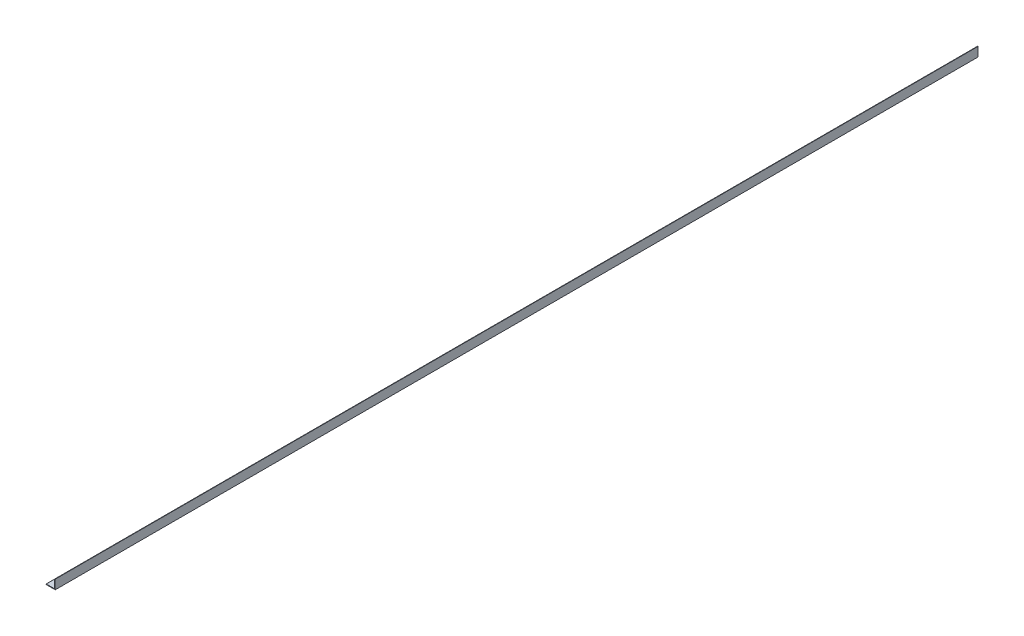
from build123d import *

# Parameters (mm, degrees)
BOSS_EXTRUDE1_DEPTH     = 1270
F_1_4_20_TAPPED_HOLE1_D = 5.1054
CUT_EXTRUDE1_DEPTH      = 2.5875


with BuildPart() as part:
    # Sketch2 → Boss-Extrude1 (new body, symmetric)
    with BuildSketch(Plane.XY):
        with BuildLine():
            Line((-12.7, -12.7), (12.7, -12.7))
            Line((12.7, -12.7), (12.7, 12.7))
            Line((12.7, 12.7), (11.90625, 12.7))
            ThreePointArc((11.90625, 12.7), (11.344983992, 12.467516008), (11.1125, 11.90625))
            Line((11.1125, 11.90625), (11.1125, -9.5377))
            ThreePointArc((11.1125, -9.5377), (10.651251759, -10.651251759), (9.5377, -11.1125))
            Line((9.5377, -11.1125), (-11.90625, -11.1125))
            ThreePointArc((-11.90625, -11.1125), (-12.467516008, -11.344983992), (-12.7, -11.90625))
            Line((-12.7, -11.90625), (-12.7, -12.7))
        make_face()
    extrude(amount=BOSS_EXTRUDE1_DEPTH, both=True)

    # 1/4-20 Tapped Hole1 (through all)
    with Locations(Plane(origin=(0, -11.1125, 0), x_dir=(1, 0, 0), z_dir=(0, 1, 0))):
        with Locations((-1.5875, -1017.524), (-1.5875, -561.848), (-1.5875, 349.504), (-1.5875, -106.172)):
            Hole(F_1_4_20_TAPPED_HOLE1_D / 2)

    # Sketch5 → Cut-Extrude1 (cut, through all)
    with BuildSketch(Plane(origin=(0, -11.1125, 0), x_dir=(1, 0, 0), z_dir=(0, 1, 0))):
        with BuildLine():
            Line((1.4605, -1057.275), (1.4605, -1076.325))
            ThreePointArc((1.4605, -1076.325), (-1.5875, -1079.373), (-4.6355, -1076.325))
            Line((-4.6355, -1076.325), (-4.6355, -1057.275))
            ThreePointArc((-4.6355, -1057.275), (-1.5875, -1054.227), (1.4605, -1057.275))
        make_face()
        with BuildLine():
            Line((1.4605, -641.35), (1.4605, -660.4))
            ThreePointArc((1.4605, -660.4), (-1.5875, -663.448), (-4.6355, -660.4))
            Line((-4.6355, -660.4), (-4.6355, -641.35))
            ThreePointArc((-4.6355, -641.35), (-1.5875, -638.302), (1.4605, -641.35))
        make_face()
        with BuildLine():
            Line((1.4605, 317.5), (1.4605, 336.55))
            ThreePointArc((1.4605, 336.55), (-1.5875, 339.598), (-4.6355, 336.55))
            Line((-4.6355, 336.55), (-4.6355, 317.5))
            ThreePointArc((-4.6355, 317.5), (-1.5875, 314.452), (1.4605, 317.5))
        make_face()
        with BuildLine():
            Line((1.4605, 717.55), (1.4605, 1092.2))
            ThreePointArc((1.4605, 1092.2), (-1.5875, 1095.248), (-4.6355, 1092.2))
            Line((-4.6355, 1092.2), (-4.6355, 717.55))
            ThreePointArc((-4.6355, 717.55), (-1.5875, 714.502), (1.4605, 717.55))
        make_face()
    extrude(amount=-CUT_EXTRUDE1_DEPTH, mode=Mode.SUBTRACT)


solid = part.part
